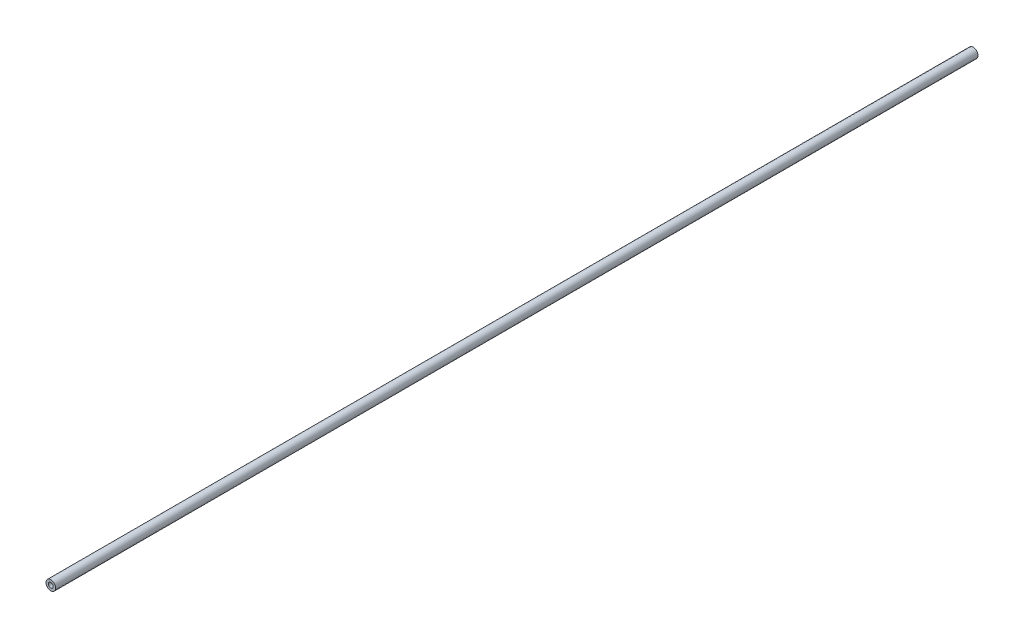
from build123d import *

# Parameters (mm, degrees)
SKETCH2_R           = 2.54
SKETCH2_R_2         = 1.27
BOSS_EXTRUDE1_DEPTH = 485.14


with BuildPart() as part:
    # Sketch2 → Boss-Extrude1 (new body)
    with BuildSketch(Plane.XY):
        Circle(SKETCH2_R)
        Circle(SKETCH2_R_2, mode=Mode.SUBTRACT)
    extrude(amount=BOSS_EXTRUDE1_DEPTH)


solid = part.part
